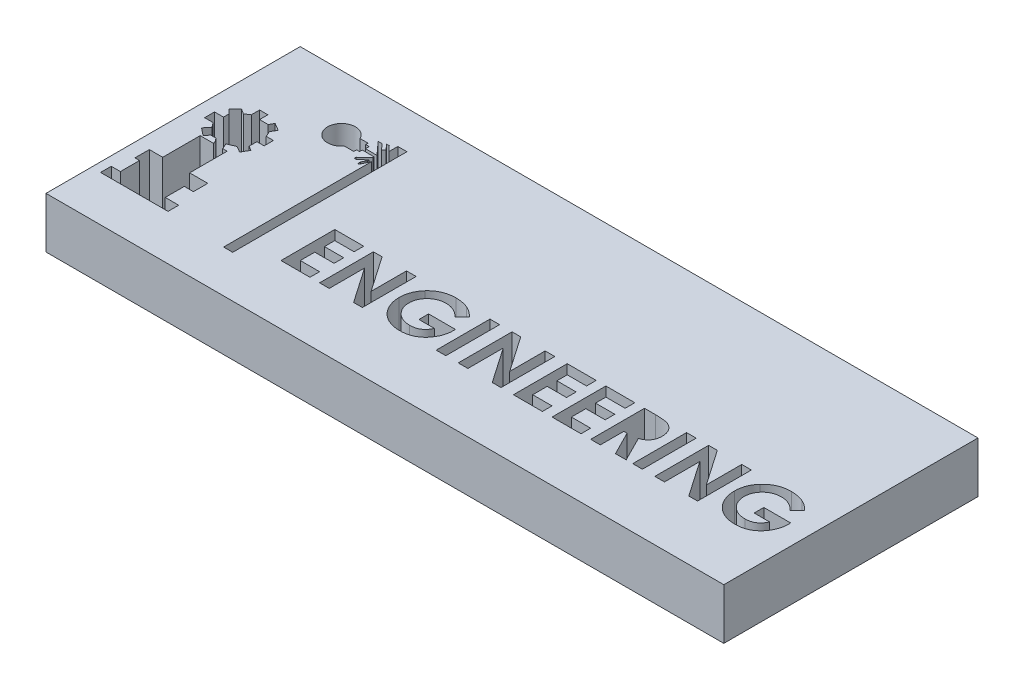
from build123d import *

# Parameters (mm, degrees)
SKETCH1_W           = 40
SKETCH1_H           = 15
SKETCH1_W_2         = 0.569871795
SKETCH1_H_2         = 3.175
BOSS_EXTRUDE1_DEPTH = 3


with BuildPart() as part:
    # Sketch1 → Boss-Extrude1 (new body)
    with BuildSketch(Plane(origin=(0, 0, 0), x_dir=(1, 0, 0), z_dir=(0, 1, 0))):
        Rectangle(SKETCH1_W, SKETCH1_H)
        Polygon((-15.478086405, -4.81981982), (-19.459459459, -4.81981982), (-19.459459459, -4.189189189), (-18.919465393, -4.189189189), (-18.919465393, -3.064077943), (-19.189462426, -3.064077943), (-19.189462426, -2.212984215), (-18.401408341, -2.212984215), (-18.401408341, 0), (-17.605820725, 0), (-17.677457308, 0.168258205), (-17.803921695, 0.336516409), (-18.116201407, 0.336516409), (-18.317882054, 0.084129102), (-18.756955536, 0.434989155), (-18.482845532, 0.778016048), (-18.684511646, 1.046328565), (-19.189462426, 1.046328565), (-19.189462426, 1.117382547), (-19.189462426, 1.635439599), (-18.660436867, 1.635439599), (-18.660436867, 1.968476275), (-18.895784708, 2.203824117), (-18.52592032, 2.573688506), (-18.240156831, 2.388756311), (-17.957359439, 2.573688506), (-17.957359439, 3.062565568), (-17.468772932, 3.062565568), (-17.468772932, 2.573688506), (-16.964053343, 2.573688506), (-16.81023311, 2.833999669), (-16.369706527, 2.573688506), (-16.561193268, 2.24963402), (-16.418034806, 1.91338702), (-15.992159883, 1.91338702), (-15.992159883, 1.36101943), (-16.418034806, 1.36101943), (-16.418034806, 0.903887632), (-16.14792409, 0.744276754), (-16.397068917, 0.322647047), (-16.753832515, 0.533461901), (-17.216413138, 0.336516409), (-17.073139973, 0), (-16.81023311, 0), (-16.81023311, -2.212984215), (-15.737114931, -2.212984215), (-15.737114931, -3.064077943), (-16.273674021, -3.064077943), (-16.273674021, -4.189189189), (-15.478086405, -4.189189189), align=None, mode=Mode.SUBTRACT)
        Polygon((-9.633653846, -4), (-9.633653846, -0.825), (-7.924038462, -0.825), (-7.924038462, -1.394871795), (-9.063782051, -1.394871795), (-9.063782051, -2.005448718), (-7.924038462, -2.005448718), (-7.924038462, -2.575320513), (-9.063782051, -2.575320513), (-9.063782051, -3.430128205), (-7.924038462, -3.430128205), (-7.924038462, -4), align=None, mode=Mode.SUBTRACT)
        Polygon((-7.354166667, -4), (-7.354166667, -0.825), (-6.840900441, -0.825), (-5.400320513, -2.914317909), (-5.400320513, -0.825), (-4.830448718, -0.825), (-4.830448718, -4), (-5.34753105, -4), (-6.784294872, -1.917042268), (-6.784294872, -4), align=None, mode=Mode.SUBTRACT)
        with BuildLine():
            add(Edge.make_bspline(
                [(-1.783288261, -0.893689904), (-1.731042052, -0.914959552), (-1.654661459, -0.954042854), (-1.555661169, -1.014256473), (-1.480907096, -1.066078177), (-1.406923145, -1.123998103), (-1.306369696, -1.209560008), (-1.235003085, -1.28059859), (-1.187975761, -1.329997997)],
                knots=[0, 0, 0, 0, 0.227396112, 0.345656643, 0.467399844, 0.594208014, 0.72467753, 1, 1, 1, 1], degree=3))
            Line((-1.187975761, -1.329997997), (-1.619195713, -1.742773438))
            add(Edge.make_bspline(
                [(-1.619195713, -1.742773438), (-1.684519175, -1.674208572), (-1.789279665, -1.580564255), (-1.9433655, -1.480033596), (-2.061081829, -1.418966167), (-2.183283397, -1.371678349), (-2.353037641, -1.325984992), (-2.485396358, -1.314168124), (-2.573858173, -1.313461538)],
                knots=[0, 0, 0, 0, 0.263807157, 0.389241238, 0.511496405, 0.632427222, 0.753438715, 1, 1, 1, 1], degree=3))
            add(Edge.make_bspline(
                [(-2.573858173, -1.313461538), (-2.650056083, -1.313841375), (-2.763154025, -1.322362651), (-2.908133238, -1.356130381), (-3.010748373, -1.390495091), (-3.108264383, -1.435261847), (-3.201244087, -1.489691389), (-3.289115852, -1.554213039), (-3.371187684, -1.627600211), (-3.445914092, -1.707724403), (-3.511155152, -1.793485573), (-3.566723045, -1.88328523), (-3.612479421, -1.977582946), (-3.647248365, -2.076233397), (-3.680970618, -2.215108056), (-3.690820139, -2.323044143), (-3.690705128, -2.395963542)],
                knots=[0, 0, 0, 0, 0.13192869, 0.195188847, 0.257128331, 0.318842593, 0.380492512, 0.443218728, 0.507125304, 0.570712137, 0.632481965, 0.693252695, 0.753131329, 0.81345766, 0.873863111, 1, 1, 1, 1], degree=3))
            add(Edge.make_bspline(
                [(-3.690705128, -2.395963542), (-3.691213531, -2.471281745), (-3.680606218, -2.582808968), (-3.645752702, -2.72632302), (-3.608246569, -2.827663534), (-3.562022107, -2.925411548), (-3.503419931, -3.017674035), (-3.435079322, -3.105859804), (-3.357127596, -3.188433602), (-3.272335922, -3.264546539), (-3.180503848, -3.330204351), (-3.084425461, -3.386849813), (-2.982549716, -3.431722359), (-2.876646223, -3.467707996), (-2.726481102, -3.502243113), (-2.609615189, -3.511473664), (-2.530608974, -3.511538462)],
                knots=[0, 0, 0, 0, 0.125850818, 0.186472088, 0.24647648, 0.306258414, 0.366951176, 0.428860876, 0.492568682, 0.55660611, 0.619086735, 0.681049201, 0.742785067, 0.804896453, 0.86784906, 1, 1, 1, 1], degree=3))
            add(Edge.make_bspline(
                [(-2.530608974, -3.511538462), (-2.479367548, -3.51229576), (-2.403935611, -3.507284834), (-2.306161308, -3.492591899), (-2.237083275, -3.478412682), (-2.171598494, -3.458308949), (-2.108799987, -3.434808354), (-2.049055779, -3.407070812), (-1.992689754, -3.374141726), (-1.938863118, -3.337232074), (-1.888079354, -3.294999738), (-1.839448974, -3.248396313), (-1.793535143, -3.196854602), (-1.751134684, -3.139905532), (-1.696261442, -3.056516336), (-1.661125433, -2.988740749), (-1.639548277, -2.941666667)],
                knots=[0, 0, 0, 0, 0.136146955, 0.200555351, 0.262793898, 0.323421562, 0.382464349, 0.440963873, 0.498292218, 0.555827999, 0.614284061, 0.673680914, 0.734765364, 0.797555301, 0.862276153, 1, 1, 1, 1], degree=3))
            Line((-1.639548277, -2.941666667), (-2.550961538, -2.941666667))
            Line((-2.550961538, -2.941666667), (-2.550961538, -2.371794872))
            Line((-2.550961538, -2.371794872), (-0.967913662, -2.371794872))
            Line((-0.967913662, -2.371794872), (-0.963461538, -2.507266627))
            add(Edge.make_bspline(
                [(-0.963461538, -2.507266627), (-0.963341591, -2.576770898), (-0.969698371, -2.680771088), (-0.992949225, -2.817225815), (-1.016580513, -2.917885221), (-1.046236526, -3.017563496), (-1.084046259, -3.115305506), (-1.128324005, -3.211774277), (-1.177933348, -3.306559844), (-1.233680175, -3.397509175), (-1.293699769, -3.483626184), (-1.35713657, -3.564761824), (-1.425370286, -3.63978567), (-1.49733841, -3.709327956), (-1.573182612, -3.773121147), (-1.653171148, -3.831219207), (-1.736880287, -3.884112985), (-1.824786835, -3.930471103), (-1.916407474, -3.970797108), (-2.011603903, -4.005042887), (-2.110621767, -4.033125489), (-2.213266716, -4.054761074), (-2.357154065, -4.075014002), (-2.467456963, -4.081712476), (-2.542057292, -4.081410256)],
                knots=[0, 0, 0, 0, 0.083832575, 0.125322447, 0.16681547, 0.208475183, 0.250643417, 0.293093669, 0.336442346, 0.379593747, 0.421656416, 0.462988405, 0.503718068, 0.543863244, 0.583608232, 0.623142924, 0.663012736, 0.702931713, 0.742887524, 0.783651685, 0.824850585, 0.866925688, 0.910065724, 1, 1, 1, 1], degree=3))
            add(Edge.make_bspline(
                [(-2.542057292, -4.081410256), (-2.62234569, -4.081537887), (-2.741541919, -4.075417563), (-2.89693802, -4.052177147), (-3.008826605, -4.028463192), (-3.117559263, -3.998913033), (-3.22294848, -3.961830195), (-3.324778891, -3.917716563), (-3.42335538, -3.867742939), (-3.517418046, -3.811068332), (-3.606756076, -3.748686725), (-3.690881847, -3.680196797), (-3.770657067, -3.606745095), (-3.844217878, -3.526526169), (-3.914305607, -3.442140301), (-3.977524733, -3.350492557), (-4.036593532, -3.254554181), (-4.089070607, -3.154365383), (-4.134962994, -3.051779179), (-4.17409842, -2.947389646), (-4.204963405, -2.840710333), (-4.230001266, -2.732486508), (-4.254118346, -2.584732601), (-4.259775573, -2.471989993), (-4.260576923, -2.396599559)],
                knots=[0, 0, 0, 0, 0.089546119, 0.132812764, 0.175102007, 0.217030183, 0.258380447, 0.299576317, 0.340707685, 0.381538295, 0.421941593, 0.462115271, 0.502433395, 0.542751519, 0.583407206, 0.624662735, 0.666792402, 0.708988356, 0.750685926, 0.792055111, 0.833202784, 0.87443934, 0.91587333, 1, 1, 1, 1], degree=3))
            add(Edge.make_bspline(
                [(-4.260576923, -2.396599559), (-4.261056462, -2.294317221), (-4.248025926, -2.142473567), (-4.204533459, -1.946102667), (-4.158563011, -1.805784039), (-4.099447835, -1.670752588), (-4.003557594, -1.495224561), (-3.911345133, -1.374753337), (-3.843985377, -1.298833133)],
                knots=[0, 0, 0, 0, 0.255241501, 0.378902227, 0.501423839, 0.623258709, 0.746437083, 1, 1, 1, 1], degree=3))
            add(Edge.make_bspline(
                [(-3.843985377, -1.298833133), (-3.803621983, -1.253014643), (-3.739571457, -1.188503177), (-3.648884521, -1.109418249), (-3.578857536, -1.05549311), (-3.506576882, -1.005413449), (-3.431859578, -0.960095356), (-3.355090931, -0.918101968), (-3.275674016, -0.881575972), (-3.194024116, -0.848827608), (-3.109779759, -0.821117292), (-3.023571823, -0.796574741), (-2.934637172, -0.777896041), (-2.843873387, -0.762373322), (-2.71817775, -0.748190014), (-2.622546328, -0.742734898), (-2.557957732, -0.743589744)],
                knots=[0, 0, 0, 0, 0.126616058, 0.188342718, 0.249479055, 0.30986417, 0.370656288, 0.430675157, 0.491277681, 0.551873821, 0.613065496, 0.675167018, 0.737704584, 0.801473299, 0.866115599, 1, 1, 1, 1], degree=3))
            add(Edge.make_bspline(
                [(-2.557957732, -0.743589744), (-2.490014249, -0.743759345), (-2.388807771, -0.748525143), (-2.255258223, -0.76361287), (-2.157472074, -0.780366265), (-2.061191751, -0.8010811), (-1.935573596, -0.836279331), (-1.843391882, -0.868705045), (-1.783288261, -0.893689904)],
                knots=[0, 0, 0, 0, 0.256614277, 0.382374861, 0.507450208, 0.631231806, 0.754220715, 1, 1, 1, 1], degree=3))
        make_face(mode=Mode.SUBTRACT)
        with Locations((-0.190064102, -2.4125)):
            Rectangle(SKETCH1_W_2, SKETCH1_H_2, mode=Mode.SUBTRACT)
        Polygon((0.827564103, -4), (0.827564103, -0.825), (1.340830329, -0.825), (2.781410256, -2.914317909), (2.781410256, -0.825), (3.351282051, -0.825), (3.351282051, -4), (2.83419972, -4), (1.397435897, -1.917042268), (1.397435897, -4), align=None, mode=Mode.SUBTRACT)
        Polygon((4.083974359, -4), (4.083974359, -0.825), (5.793589744, -0.825), (5.793589744, -1.394871795), (4.653846154, -1.394871795), (4.653846154, -2.005448718), (5.793589744, -2.005448718), (5.793589744, -2.575320513), (4.653846154, -2.575320513), (4.653846154, -3.430128205), (5.793589744, -3.430128205), (5.793589744, -4), align=None, mode=Mode.SUBTRACT)
        Polygon((6.363461538, -4), (6.363461538, -0.825), (8.073076923, -0.825), (8.073076923, -1.394871795), (6.933333333, -1.394871795), (6.933333333, -2.005448718), (8.073076923, -2.005448718), (8.073076923, -2.575320513), (6.933333333, -2.575320513), (6.933333333, -3.430128205), (8.073076923, -3.430128205), (8.073076923, -4), align=None, mode=Mode.SUBTRACT)
        with BuildLine():
            Line((8.642948718, -4), (8.642948718, -0.825))
            Line((8.642948718, -0.825), (9.306951122, -0.825))
            add(Edge.make_bspline(
                [(9.306951122, -0.825), (9.391368153, -0.824542004), (9.513158229, -0.827545344), (9.668790908, -0.836770289), (9.77086937, -0.846797358), (9.863166234, -0.860110081), (9.945774084, -0.875799787), (10.018690488, -0.893682415), (10.082530398, -0.915965375), (10.14014276, -0.94110026), (10.193845492, -0.969980692), (10.244823354, -1.002285092), (10.292735616, -1.038863472), (10.337998644, -1.079057798), (10.380697836, -1.122908527), (10.420229796, -1.170787498), (10.456349795, -1.222392173), (10.489270113, -1.276679112), (10.51836534, -1.333722835), (10.542023499, -1.393563072), (10.562936215, -1.455334769), (10.577968736, -1.519921868), (10.59228845, -1.610372049), (10.597687036, -1.679836266), (10.596794872, -1.726872997)],
                knots=[0, 0, 0, 0, 0.14018613, 0.202277434, 0.258895132, 0.310482942, 0.357095244, 0.398513567, 0.435037511, 0.469251486, 0.502805028, 0.536210446, 0.56937936, 0.602801475, 0.636665798, 0.670928657, 0.705803, 0.741189061, 0.776304311, 0.812004301, 0.847968976, 0.884521761, 0.921974159, 1, 1, 1, 1], degree=3))
            add(Edge.make_bspline(
                [(10.596794872, -1.726872997), (10.596038286, -1.775913829), (10.592972678, -1.848324159), (10.577612786, -1.942035623), (10.560539669, -2.007683065), (10.540906196, -2.070827191), (10.514801672, -2.130301926), (10.485339463, -2.186972504), (10.450348252, -2.240037259), (10.411947028, -2.290674767), (10.367287353, -2.336945352), (10.319261881, -2.381334172), (10.265173268, -2.421067354), (10.207396821, -2.458805679), (10.122250278, -2.505448349), (10.053999861, -2.534446143), (10.006570513, -2.551151843)],
                knots=[0, 0, 0, 0, 0.134789088, 0.19853605, 0.260385651, 0.320961578, 0.37990385, 0.438502936, 0.496154344, 0.554265483, 0.612748761, 0.672513443, 0.733646402, 0.796789619, 0.861935699, 1, 1, 1, 1], degree=3))
            Line((10.006570513, -2.551151843), (10.739262821, -4))
            Line((10.739262821, -4), (10.105789263, -4))
            Line((10.105789263, -4), (9.406169872, -2.616025641))
            Line((9.406169872, -2.616025641), (9.212820513, -2.616025641))
            Line((9.212820513, -2.616025641), (9.212820513, -4))
            Line((9.212820513, -4), (8.642948718, -4))
        make_face(mode=Mode.SUBTRACT)
        with Locations((11.410897436, -2.4125)):
            Rectangle(SKETCH1_W_2, SKETCH1_H_2, mode=Mode.SUBTRACT)
        Polygon((12.428525641, -4), (12.428525641, -0.825), (12.941791867, -0.825), (14.382371795, -2.914317909), (14.382371795, -0.825), (14.95224359, -0.825), (14.95224359, -4), (14.435161258, -4), (12.998397436, -1.917042268), (12.998397436, -4), align=None, mode=Mode.SUBTRACT)
        with BuildLine():
            add(Edge.make_bspline(
                [(17.999404046, -0.893689904), (18.051650256, -0.914959552), (18.128030849, -0.954042854), (18.227031139, -1.014256473), (18.301785212, -1.066078177), (18.375769163, -1.123998103), (18.476322612, -1.209560008), (18.547689223, -1.28059859), (18.594716546, -1.329997997)],
                knots=[0, 0, 0, 0, 0.227396112, 0.345656643, 0.467399844, 0.594208014, 0.72467753, 1, 1, 1, 1], degree=3))
            Line((18.594716546, -1.329997997), (18.163496595, -1.742773437))
            add(Edge.make_bspline(
                [(18.163496595, -1.742773437), (18.098173133, -1.674208572), (17.993412643, -1.580564255), (17.839326807, -1.480033596), (17.721610479, -1.418966167), (17.599408911, -1.371678349), (17.429654667, -1.325984992), (17.29729595, -1.314168124), (17.208834135, -1.313461538)],
                knots=[0, 0, 0, 0, 0.263807157, 0.389241238, 0.511496405, 0.632427222, 0.753438715, 1, 1, 1, 1], degree=3))
            add(Edge.make_bspline(
                [(17.208834135, -1.313461538), (17.132636225, -1.313841375), (17.019538283, -1.322362651), (16.87455907, -1.356130381), (16.771943934, -1.390495091), (16.674427925, -1.435261847), (16.581448221, -1.489691389), (16.493576456, -1.554213039), (16.411504624, -1.627600211), (16.336778216, -1.707724403), (16.271537155, -1.793485573), (16.215969262, -1.88328523), (16.170212887, -1.977582946), (16.135443943, -2.076233397), (16.10172169, -2.215108056), (16.091872168, -2.323044143), (16.091987179, -2.395963542)],
                knots=[0, 0, 0, 0, 0.13192869, 0.195188847, 0.257128331, 0.318842593, 0.380492512, 0.443218728, 0.507125304, 0.570712137, 0.632481965, 0.693252695, 0.753131329, 0.81345766, 0.873863111, 1, 1, 1, 1], degree=3))
            add(Edge.make_bspline(
                [(16.091987179, -2.395963542), (16.091478776, -2.471281745), (16.102086089, -2.582808968), (16.136939606, -2.72632302), (16.174445738, -2.827663534), (16.220670201, -2.925411548), (16.279272376, -3.017674035), (16.347612986, -3.105859804), (16.425564712, -3.188433602), (16.510356386, -3.264546539), (16.60218846, -3.330204351), (16.698266847, -3.386849813), (16.800142592, -3.431722359), (16.906046085, -3.467707996), (17.056211205, -3.502243113), (17.173077118, -3.511473664), (17.252083333, -3.511538462)],
                knots=[0, 0, 0, 0, 0.125850818, 0.186472088, 0.24647648, 0.306258414, 0.366951176, 0.428860876, 0.492568682, 0.55660611, 0.619086735, 0.681049201, 0.742785067, 0.804896453, 0.86784906, 1, 1, 1, 1], degree=3))
            add(Edge.make_bspline(
                [(17.252083333, -3.511538462), (17.303324759, -3.51229576), (17.378756696, -3.507284834), (17.476531, -3.492591899), (17.545609032, -3.478412682), (17.611093813, -3.458308949), (17.673892321, -3.434808354), (17.733636528, -3.407070812), (17.790002553, -3.374141726), (17.84382919, -3.337232074), (17.894612954, -3.294999738), (17.943243334, -3.248396313), (17.989157165, -3.196854602), (18.031557623, -3.139905532), (18.086430866, -3.056516336), (18.121566874, -2.988740749), (18.14314403, -2.941666667)],
                knots=[0, 0, 0, 0, 0.136146955, 0.200555351, 0.262793898, 0.323421562, 0.382464349, 0.440963873, 0.498292218, 0.555827999, 0.614284061, 0.673680914, 0.734765364, 0.797555301, 0.862276153, 1, 1, 1, 1], degree=3))
            Line((18.14314403, -2.941666667), (17.231730769, -2.941666667))
            Line((17.231730769, -2.941666667), (17.231730769, -2.371794872))
            Line((17.231730769, -2.371794872), (18.814778646, -2.371794872))
            Line((18.814778646, -2.371794872), (18.819230769, -2.507266627))
            add(Edge.make_bspline(
                [(18.819230769, -2.507266627), (18.819350717, -2.576770898), (18.812993936, -2.680771088), (18.789743083, -2.817225815), (18.766111795, -2.917885221), (18.736455782, -3.017563496), (18.698646049, -3.115305506), (18.654368303, -3.211774277), (18.60475896, -3.306559844), (18.549012133, -3.397509175), (18.488992539, -3.483626184), (18.425555738, -3.564761824), (18.357322022, -3.63978567), (18.285353897, -3.709327956), (18.209509696, -3.773121147), (18.12952116, -3.831219207), (18.045812021, -3.884112985), (17.957905472, -3.930471103), (17.866284833, -3.970797108), (17.771088405, -4.005042887), (17.672070541, -4.033125489), (17.569425592, -4.054761074), (17.425538242, -4.075014002), (17.315235345, -4.081712476), (17.240635016, -4.081410256)],
                knots=[0, 0, 0, 0, 0.083832575, 0.125322447, 0.16681547, 0.208475183, 0.250643417, 0.293093669, 0.336442346, 0.379593747, 0.421656416, 0.462988405, 0.503718068, 0.543863244, 0.583608232, 0.623142924, 0.663012736, 0.702931713, 0.742887524, 0.783651685, 0.824850585, 0.866925688, 0.910065724, 1, 1, 1, 1], degree=3))
            add(Edge.make_bspline(
                [(17.240635016, -4.081410256), (17.160346618, -4.081537887), (17.041150389, -4.075417563), (16.885754287, -4.052177147), (16.773865703, -4.028463192), (16.665133045, -3.998913033), (16.559743827, -3.961830195), (16.457913417, -3.917716563), (16.359336928, -3.867742939), (16.265274262, -3.811068332), (16.175936232, -3.748686725), (16.091810461, -3.680196797), (16.012035241, -3.606745095), (15.93847443, -3.526526169), (15.8683867, -3.442140301), (15.805167574, -3.350492557), (15.746098776, -3.254554181), (15.6936217, -3.154365383), (15.647729314, -3.051779179), (15.608593888, -2.947389646), (15.577728903, -2.840710333), (15.552691042, -2.732486508), (15.528573962, -2.584732601), (15.522916735, -2.471989993), (15.522115385, -2.396599559)],
                knots=[0, 0, 0, 0, 0.089546119, 0.132812764, 0.175102007, 0.217030183, 0.258380447, 0.299576317, 0.340707685, 0.381538295, 0.421941593, 0.462115271, 0.502433395, 0.542751519, 0.583407206, 0.624662735, 0.666792402, 0.708988356, 0.750685926, 0.792055111, 0.833202784, 0.87443934, 0.91587333, 1, 1, 1, 1], degree=3))
            add(Edge.make_bspline(
                [(15.522115385, -2.396599559), (15.521635846, -2.294317221), (15.534666381, -2.142473567), (15.578158849, -1.946102667), (15.624129297, -1.805784039), (15.683244472, -1.670752588), (15.779134714, -1.495224561), (15.871347175, -1.374753337), (15.938706931, -1.298833133)],
                knots=[0, 0, 0, 0, 0.255241501, 0.378902227, 0.501423839, 0.623258709, 0.746437083, 1, 1, 1, 1], degree=3))
            add(Edge.make_bspline(
                [(15.938706931, -1.298833133), (15.979070324, -1.253014643), (16.04312085, -1.188503177), (16.133807787, -1.109418249), (16.203834772, -1.05549311), (16.276115426, -1.005413449), (16.350832729, -0.960095356), (16.427601377, -0.918101968), (16.507018291, -0.881575972), (16.588668192, -0.848827608), (16.672912549, -0.821117292), (16.759120485, -0.796574741), (16.848055136, -0.777896041), (16.93881892, -0.762373322), (17.064514558, -0.748190014), (17.16014598, -0.742734898), (17.224734575, -0.743589744)],
                knots=[0, 0, 0, 0, 0.126616058, 0.188342718, 0.249479055, 0.30986417, 0.370656288, 0.430675157, 0.491277681, 0.551873821, 0.613065496, 0.675167018, 0.737704584, 0.801473299, 0.866115599, 1, 1, 1, 1], degree=3))
            add(Edge.make_bspline(
                [(17.224734575, -0.743589744), (17.292678059, -0.743759345), (17.393884536, -0.748525143), (17.527434085, -0.76361287), (17.625220234, -0.780366265), (17.721500556, -0.8010811), (17.847118711, -0.836279331), (17.939300426, -0.868705045), (17.999404046, -0.893689904)],
                knots=[0, 0, 0, 0, 0.256614277, 0.382374861, 0.507450208, 0.631231806, 0.754220715, 1, 1, 1, 1], degree=3))
        make_face(mode=Mode.SUBTRACT)
        with BuildLine():
            Line((-13.535287541, 4.56966211), (-13.060411066, 4.56966211))
            Line((-13.060411066, 4.56966211), (-13.060411066, 4.428027833))
            Line((-13.060411066, 4.428027833), (-12.857523036, 4.428027833))
            Line((-12.857523036, 4.428027833), (-12.857523036, 4.209531545))
            Line((-12.857523036, 4.209531545), (-12.177280784, 4.209531545))
            Line((-12.177280784, 4.209531545), (-12.857523036, 4.956373266))
            Line((-12.857523036, 4.956373266), (-12.623504943, 4.956373266))
            Line((-12.623504943, 4.956373266), (-12.315637722, 4.618364146))
            Line((-12.315637722, 4.618364146), (-12.177280784, 4.74438313))
            Line((-12.177280784, 4.74438313), (-12.469571333, 5.065290536))
            Line((-12.469571333, 5.065290536), (-12.30842909, 5.065290536))
            Line((-12.30842909, 5.065290536), (-12.016138541, 4.74438313))
            Line((-12.016138541, 4.74438313), (-12.016138541, 5.278781452))
            Line((-12.016138541, 5.278781452), (-11.478297092, 5.278781452))
            Line((-11.478297092, 5.278781452), (-11.478297092, -5.004155971))
            Line((-11.478297092, -5.004155971), (-12.016138541, -5.004155971))
            Line((-12.016138541, -5.004155971), (-12.016138541, 3.721894304))
            Line((-12.016138541, 3.721894304), (-12.250353421, 3.221990326))
            Line((-12.250353421, 3.221990326), (-12.323426058, 3.221990326))
            Line((-12.323426058, 3.221990326), (-12.323426058, 3.387966114))
            Line((-12.323426058, 3.387966114), (-12.177280784, 3.654739412))
            Line((-12.177280784, 3.654739412), (-12.177280784, 3.745517778))
            Line((-12.177280784, 3.745517778), (-12.569838728, 3.387966114))
            Line((-12.569838728, 3.387966114), (-12.697916309, 3.387966114))
            Line((-12.697916309, 3.387966114), (-12.697916309, 3.494152547))
            Line((-12.697916309, 3.494152547), (-12.177280784, 3.968360498))
            Line((-12.177280784, 3.968360498), (-12.177280784, 4.046466218))
            Line((-12.177280784, 4.046466218), (-12.881659126, 4.046466218))
            Line((-12.881659126, 4.046466218), (-12.881659126, 3.890254779))
            Line((-12.881659126, 3.890254779), (-13.060411066, 3.890254779))
            Line((-13.060411066, 3.890254779), (-13.060411066, 3.721894304))
            Line((-13.060411066, 3.721894304), (-13.612519776, 3.721894304))
            ThreePointArc((-13.612519776, 3.721894304), (-15.091892702, 4.284068063), (-13.535287541, 4.56966211))
        make_face(mode=Mode.SUBTRACT)
    extrude(amount=BOSS_EXTRUDE1_DEPTH)


solid = part.part
